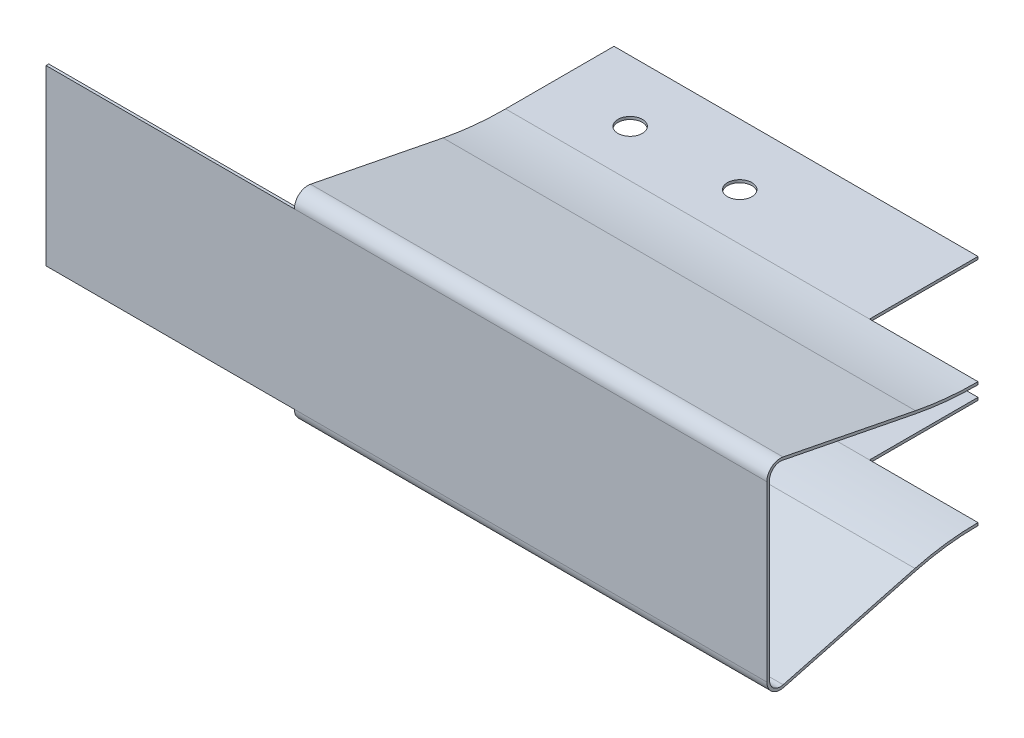
from build123d import *

# Parameters (mm, degrees)
EXTRUDE1_DEPTH          = 66.46
SKETCH2_W               = 45.8
SKETCH2_H               = 1.25
CUT_EXTRUDE1_DEPTH      = 25.47
SKETCH3_W               = 45.8
SKETCH3_H               = 29.22
CUT_EXTRUDE2_DEPTH      = 10.25
CUT_EXTRUDE2_DEPTH_BACK = 10.25
SKETCH4_R               = 1.125
SKETCH4_W               = 10
SKETCH4_H               = 10
CUT_EXTRUDE3_DEPTH      = 10.25
CUT_EXTRUDE3_DEPTH_BACK = 10.25
SKETCH5_W               = 66.46
SKETCH5_H               = 29.47
CUT_EXTRUDE4_DEPTH      = 10.25
CUT_EXTRUDE4_DEPTH_BACK = 10.25


with BuildPart() as part:
    # Sketch1 → Extrude1 (new body, symmetric)
    with BuildSketch(Plane(origin=(0, 0, 0), x_dir=(0, 0, -1), z_dir=(1, 0, 0))):
        with BuildLine():
            Line((-24.22, 8), (-24.22, -8))
            ThreePointArc((-24.22, -8), (-23.830111825, -8.792315317), (-22.964472878, -8.966801888))
            Line((-22.964472878, -8.966801888), (-10.813561051, -5.755298505))
            ThreePointArc((-10.813561051, -5.755298505), (-7.931209986, -5.189614776), (-5, -5))
            Line((-5, -5), (5, -5))
            Line((5, -5), (5, -5.25))
            Line((5, -5.25), (-5, -5.25))
            ThreePointArc((-5, -5.25), (-7.899000655, -5.437531211), (-10.749679271, -5.996998977))
            Line((-10.749679271, -5.996998977), (-22.900591097, -9.208502359))
            ThreePointArc((-22.900591097, -9.208502359), (-23.982639781, -8.990394146), (-24.47, -8))
            Line((-24.47, -8), (-24.47, 8))
            ThreePointArc((-24.47, 8), (-24.013634161, 8.965735377), (-22.97776829, 9.226304937))
            Line((-22.97776829, 9.226304937), (-10.765114709, 6.8139425))
            ThreePointArc((-10.765114709, 6.8139425), (-7.896315709, 6.391321284), (-5, 6.25))
            Line((-5, 6.25), (5, 6.25))
            Line((5, 6.25), (5, 6))
            Line((5, 6), (-5, 6))
            ThreePointArc((-5, 6), (-7.920654497, 6.142508858), (-10.813561051, 6.568681513))
            Line((-10.813561051, 6.568681513), (-23.026214632, 8.98104395))
            ThreePointArc((-23.026214632, 8.98104395), (-23.854907329, 8.772588302), (-24.22, 8))
        make_face()
    extrude(amount=EXTRUDE1_DEPTH, both=True)

    # Sketch2 → Cut-Extrude1 (cut, through all)
    with BuildSketch(Plane.XY):
        with Locations((0, 8.625)):
            Rectangle(SKETCH2_W, SKETCH2_H)
        with Locations((0, -8.625)):
            Rectangle(SKETCH2_W, SKETCH2_H)
    extrude(amount=CUT_EXTRUDE1_DEPTH, mode=Mode.SUBTRACT)

    # Sketch3 → Cut-Extrude2 (cut, two sides)
    with BuildSketch(Plane(origin=(0, 0, 0), x_dir=(1, 0, 0), z_dir=(0, 1, 0))) as cut_extrude2_sk:
        with Locations((0, -9.61)):
            Rectangle(SKETCH3_W, SKETCH3_H)
    extrude(amount=CUT_EXTRUDE2_DEPTH, mode=Mode.SUBTRACT)
    extrude(cut_extrude2_sk.sketch, amount=-CUT_EXTRUDE2_DEPTH_BACK, mode=Mode.SUBTRACT)

    # Sketch4 → Cut-Extrude3 (cut, two sides)
    with BuildSketch(Plane(origin=(0, 0, 0), x_dir=(1, 0, 0), z_dir=(0, 1, 0))) as cut_extrude3_sk:
        with Locations(Location((-40.14, -0.65, 0), (0, 0, 270))):  # turned: the seam where the file's is
            Circle(SKETCH4_R)
        with Locations(Location((-30.04, -0.65, 0), (0, 0, 270))):  # turned: the seam where the file's is
            Circle(SKETCH4_R)
        with Locations(Location((30.04, -0.65, 0), (0, 0, 270))):  # turned: the seam where the file's is
            Circle(SKETCH4_R)
        with Locations(Location((40.14, -0.65, 0), (0, 0, 270))):  # turned: the seam where the file's is
            Circle(SKETCH4_R)
        with Locations((-61.46, 0)):
            Rectangle(SKETCH4_W, SKETCH4_H)
        with Locations((61.46, 0)):
            Rectangle(SKETCH4_W, SKETCH4_H)
    extrude(amount=CUT_EXTRUDE3_DEPTH, mode=Mode.SUBTRACT)
    extrude(cut_extrude3_sk.sketch, amount=-CUT_EXTRUDE3_DEPTH_BACK, mode=Mode.SUBTRACT)

    # Sketch5 → Cut-Extrude4 (cut, two sides)
    with BuildSketch(Plane(origin=(0, 0, 0), x_dir=(1, 0, 0), z_dir=(0, 1, 0))) as cut_extrude4_sk:
        with Locations((-33.23, -9.735)):
            Rectangle(SKETCH5_W, SKETCH5_H)
    extrude(amount=CUT_EXTRUDE4_DEPTH, mode=Mode.SUBTRACT)
    extrude(cut_extrude4_sk.sketch, amount=-CUT_EXTRUDE4_DEPTH_BACK, mode=Mode.SUBTRACT)


solid = part.part
